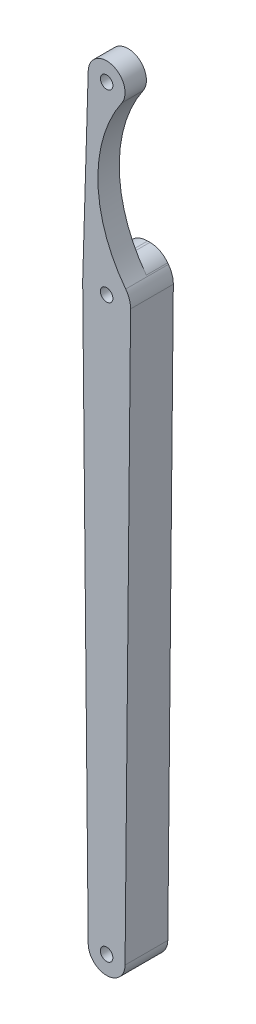
from build123d import *

# Parameters (mm, degrees)
SKETCH_1_R          = 1.7
EXTRUDE_1_DEPTH     = 5.8
SKETCH_2_W          = 5.8
SKETCH_2_H          = 48.387548751
CUT_EXTRUDE_1_DEPTH = 279.6
FILLET_1_R          = 6


with BuildPart() as part:
    # 草图1 → 凸台-拉伸1 (new body, symmetric)
    with BuildSketch(Plane.XY):
        with BuildLine():
            Line((-181.16239443, 23.937096774), (-179.662464671, -131.048387097))
            ThreePointArc((-179.662464671, -131.048387097), (-174.662698808, -136), (-169.662932944, -131.048387097))
            Line((-169.662932944, -131.048387097), (-168.163003185, 23.937096774))
            ThreePointArc((-168.163003185, 23.937096774), (-168.494379467, 26.049838166), (-169.49346521, 27.940688267))
            ThreePointArc((-169.49346521, 27.940688267), (-177.025820297, 49.382777319), (-170.5438245, 71.165414592))
            ThreePointArc((-170.5438245, 71.165414592), (-173.107050096, 78.751837233), (-179.660448301, 74.15))
            Line((-179.660448301, 74.15), (-181.159773149, 24.195))
            ThreePointArc((-181.159773149, 24.195), (-181.162363098, 24.06606139), (-181.16239443, 23.937096774))
        make_face()
        with Locations((-174.662698808, 24)):
            Circle(SKETCH_1_R, mode=Mode.SUBTRACT)
        with Locations((-174.662698808, -131)):
            Circle(SKETCH_1_R, mode=Mode.SUBTRACT)
        with Locations((-174.662698808, 74)):
            Circle(SKETCH_1_R, mode=Mode.SUBTRACT)
    extrude(amount=EXTRUDE_1_DEPTH, both=True)

    # 草图2 → 切除-拉伸1 (cut)
    with BuildSketch(Plane(origin=(0, 0, 0), x_dir=(0, 0, -1), z_dir=(1, 0, 0))):
        with Locations((2.9, 54.806225625)):
            Rectangle(SKETCH_2_W, SKETCH_2_H)
    extrude(amount=-CUT_EXTRUDE_1_DEPTH, mode=Mode.SUBTRACT)

    # 圆角1
    fillet_1_edges = [part.edges().sort_by_distance(p)[0] for p in [
        (-180.967162918, 30.612451249, -2.9),
        (-171.349640462, 30.612451249, -2.9),
    ]]
    fillet(fillet_1_edges, radius=FILLET_1_R)


solid = part.part
